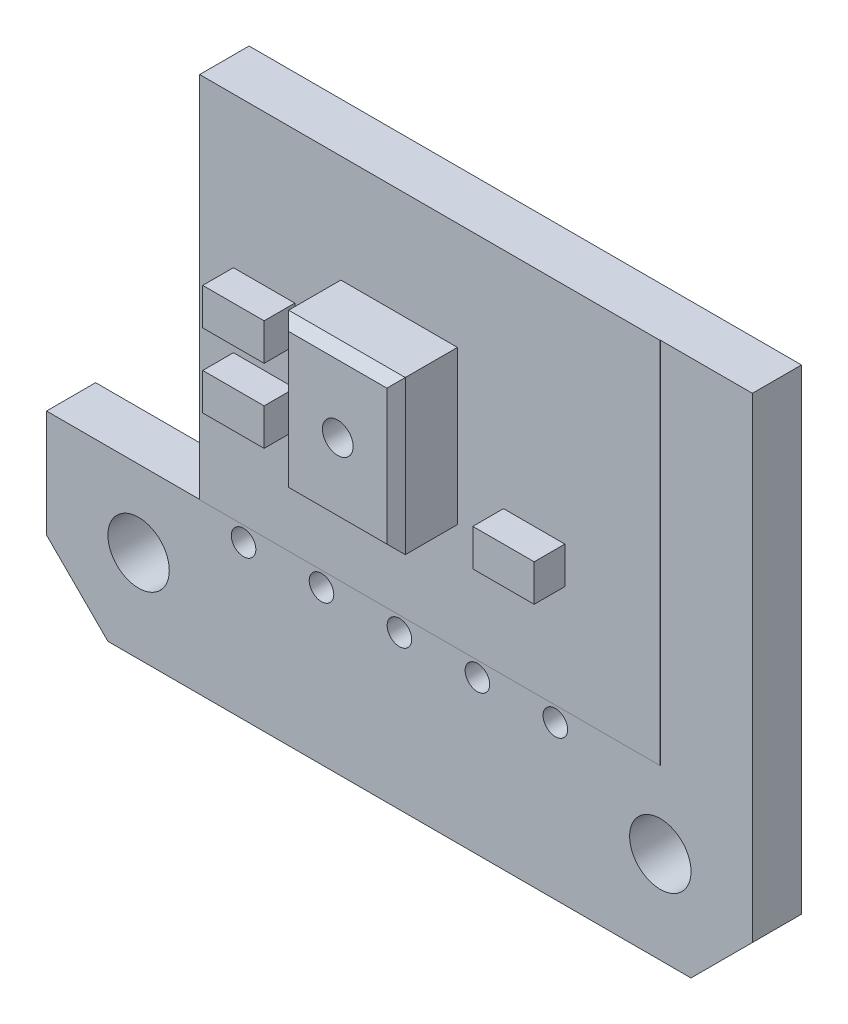
from build123d import *

# Parameters (mm, degrees)
BOSS_EXTRUDE1_DEPTH = 1.6
SKETCH2_W           = 17
SKETCH2_H           = 12
BOSS_EXTRUDE2_DEPTH = 1.61
SKETCH3_R           = 0.4
CUT_EXTRUDE1_DEPTH  = 2.62
BOSS_EXTRUDE4_START = 1.61
SKETCH4_W           = 3.8
SKETCH4_H           = 5
BOSS_EXTRUDE4_DEPTH = 2
BOSS_EXTRUDE5_START = 1.61
SKETCH5_W           = 2
SKETCH5_H           = 1.2
BOSS_EXTRUDE5_DEPTH = 1
CHAMFER1_SIZE       = 0.3
SKETCH8_R           = 1
CUT_EXTRUDE2_DEPTH  = 3.5
SKETCH9_W           = 23
SKETCH9_H           = 5.5
CUT_EXTRUDE3_DEPTH  = 3.5
SKETCH10_W          = 5
SKETCH10_H          = 12
CUT_EXTRUDE4_DEPTH  = 3.5
SKETCH11_R          = 0.5
CUT_EXTRUDE5_DEPTH  = 5


with BuildPart() as part:
    # Sketch1 → Boss-Extrude1 (new body)
    with BuildSketch(Plane.XY):
        Polygon((-11.5, 9.5), (-9.5, 11.5), (9.5, 11.5), (11.5, 9.5), (11.5, -9.5), (9.5, -11.5), (-9.5, -11.5), (-11.5, -9.5), align=None)
    extrude(amount=BOSS_EXTRUDE1_DEPTH)

    # Sketch2 → Boss-Extrude2 (add)
    with BuildSketch(Plane.XY):
        Rectangle(SKETCH2_W, SKETCH2_H)
    extrude(amount=BOSS_EXTRUDE2_DEPTH)

    # Sketch3 → Cut-Extrude1 (cut)
    with BuildSketch(Plane.XY):
        with Locations((-5.08, -6.5)):
            Circle(SKETCH3_R)
        with Locations((-2.54, -6.5)):
            Circle(SKETCH3_R)
        with Locations((0, -6.5)):
            Circle(SKETCH3_R)
        with Locations((2.54, -6.5)):
            Circle(SKETCH3_R)
        with Locations((5.08, -6.5)):
            Circle(SKETCH3_R)
    extrude(amount=CUT_EXTRUDE1_DEPTH, mode=Mode.SUBTRACT)

    # Sketch4 → Boss-Extrude4 (add)
    with BuildSketch(Plane.XY.offset(BOSS_EXTRUDE4_START)):
        Rectangle(SKETCH4_W, SKETCH4_H)
    extrude(amount=BOSS_EXTRUDE4_DEPTH)

    # Sketch5 → Boss-Extrude5 (add)
    with BuildSketch(Plane.XY.offset(BOSS_EXTRUDE5_START)):
        with Locations((-4.4, -1.9)):
            Rectangle(SKETCH5_W, SKETCH5_H)
        with Locations((-4.4, 0.5)):
            Rectangle(SKETCH5_W, SKETCH5_H)
        with Locations((4.4, -1.9)):
            Rectangle(SKETCH5_W, SKETCH5_H)
    extrude(amount=BOSS_EXTRUDE5_DEPTH)

    # Chamfer1
    chamfer1_edges = [part.edges().sort_by_distance(p)[0] for p in [
        (1.9, 0, 3.61),
        (0, 2.5, 3.61),
        (-1.9, 0, 3.61),
        (0, -2.5, 3.61),
    ]]
    chamfer(chamfer1_edges, length=CHAMFER1_SIZE)

    # Sketch8 → Cut-Extrude2 (cut, symmetric)
    with BuildSketch(Plane.XY):
        with Locations((8.5, -8.5)):
            Circle(SKETCH8_R)
        with Locations((-8.5, -8.5)):
            Circle(SKETCH8_R)
        with Locations((8.5, 8.5)):
            Circle(SKETCH8_R)
        with Locations((-8.5, 8.5)):
            Circle(SKETCH8_R)
    extrude(amount=CUT_EXTRUDE2_DEPTH, both=True, mode=Mode.SUBTRACT)

    # Sketch9 → Cut-Extrude3 (cut, symmetric)
    with BuildSketch(Plane.XY):
        with Locations((0, 8.75)):
            Rectangle(SKETCH9_W, SKETCH9_H)
    extrude(amount=CUT_EXTRUDE3_DEPTH, both=True, mode=Mode.SUBTRACT)

    # Sketch10 → Cut-Extrude4 (cut, symmetric)
    with BuildSketch(Plane.XY):
        with Locations((-9, 0)):
            Rectangle(SKETCH10_W, SKETCH10_H)
    extrude(amount=CUT_EXTRUDE4_DEPTH, both=True, mode=Mode.SUBTRACT)

    # Sketch11 → Cut-Extrude5 (cut, symmetric)
    with BuildSketch(Plane.XY):
        Circle(SKETCH11_R)
    extrude(amount=CUT_EXTRUDE5_DEPTH, both=True, mode=Mode.SUBTRACT)


solid = part.part
